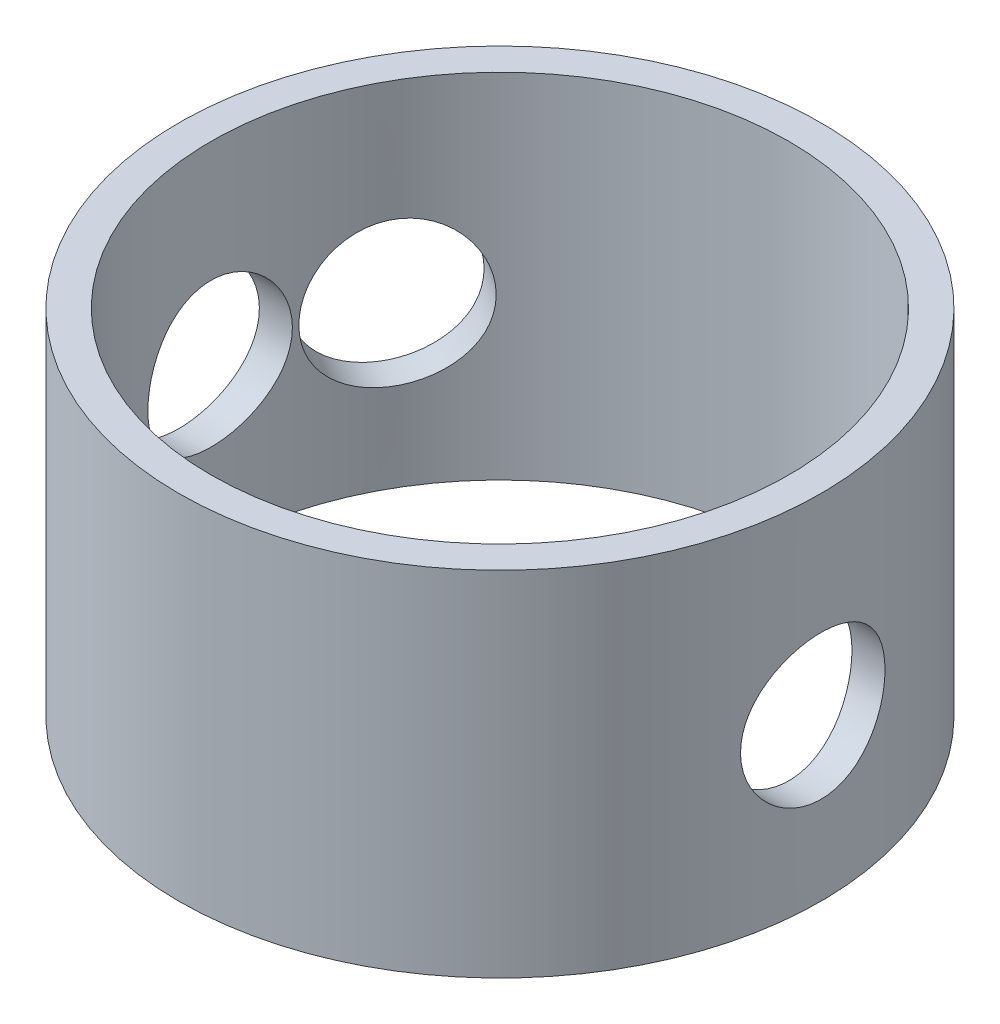
from build123d import *

# Parameters (mm, degrees)
ESBO_O1_R                     = 10
ESBO_O1_R_2                   = 9
RESSALTO_EXTRUS_O1_DEPTH      = 6
RESSALTO_EXTRUS_O1_DEPTH_BACK = 5
CORTE_EXTRUS_O1_REACH         = 25.66
ESBO_O2_R                     = 2.25
ESBO_O3_R                     = 2.25
CORTE_EXTRUS_O2_DEPTH         = 11.0000001
CORTE_EXTRUS_O2_DEPTH_BACK    = 11.0000001


with BuildPart() as part:
    # Esboço1 → Ressalto-extrusão1 (new body, two sides)
    with BuildSketch(Plane(origin=(0, 0, 0), x_dir=(1, 0, 0), z_dir=(0, 1, 0))) as ressalto_extrus_o1_sk:
        Circle(ESBO_O1_R)
        Circle(ESBO_O1_R_2, mode=Mode.SUBTRACT)
    extrude(amount=RESSALTO_EXTRUS_O1_DEPTH)
    extrude(ressalto_extrus_o1_sk.sketch, amount=-RESSALTO_EXTRUS_O1_DEPTH_BACK)

    # Esboço2 → Corte-extrusão1 (cut, up to next)
    with BuildSketch(Plane(origin=(-8.660254038, 0, -5), x_dir=(-0.5, 0, 0.866025404), z_dir=(-0.866025404, 0, -0.5)), mode=Mode.PRIVATE) as corte_extrus_o1_sk1:
        Circle(ESBO_O2_R)
    corte_extrus_o1_tool1 = extrude(corte_extrus_o1_sk1.sketch, amount=-CORTE_EXTRUS_O1_REACH, mode=Mode.PRIVATE) & part.part
    add(corte_extrus_o1_tool1.solids().sort_by_distance((-8.660254, 0, -5))[0], mode=Mode.SUBTRACT)

    # Esboço3 → Corte-extrusão2 (cut, two sides)
    with BuildSketch(Plane(origin=(0, 0, 0), x_dir=(0, 0, -1), z_dir=(1, 0, 0))) as corte_extrus_o2_sk:
        Circle(ESBO_O3_R)
    extrude(amount=CORTE_EXTRUS_O2_DEPTH, mode=Mode.SUBTRACT)
    extrude(corte_extrus_o2_sk.sketch, amount=-CORTE_EXTRUS_O2_DEPTH_BACK, mode=Mode.SUBTRACT)


solid = part.part
